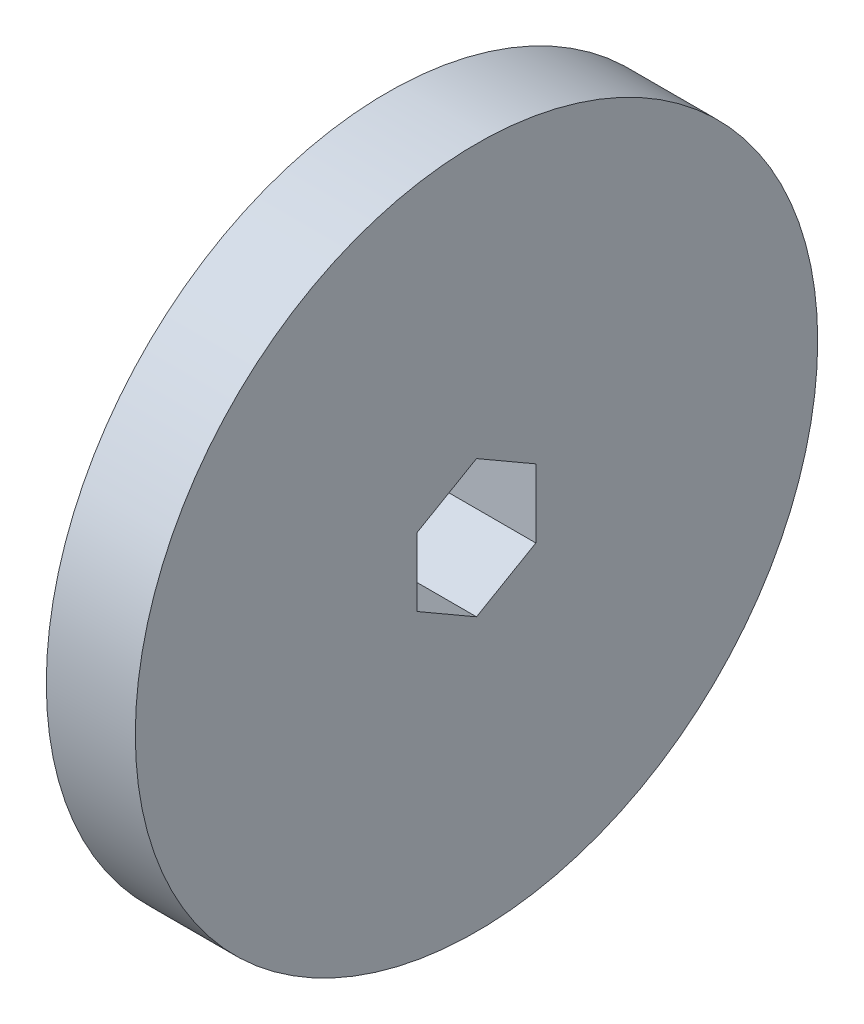
from build123d import *

# Parameters (mm, degrees)
SKETCH2_R           = 36.5125
BOSS_EXTRUDE1_DEPTH = 4.7625


with BuildPart() as part:
    # Sketch2 → Boss-Extrude1 (new body, symmetric)
    with BuildSketch(Plane(origin=(0, 0, 0), x_dir=(0, 0, -1), z_dir=(1, 0, 0))):
        Circle(SKETCH2_R)
        Polygon((0, 7.332348419), (-6.35, 3.666174209), (-6.35, -3.666174209), (0, -7.332348419), (6.35, -3.666174209), (6.35, 3.666174209), align=None, mode=Mode.SUBTRACT)
    extrude(amount=BOSS_EXTRUDE1_DEPTH, both=True)


solid = part.part
